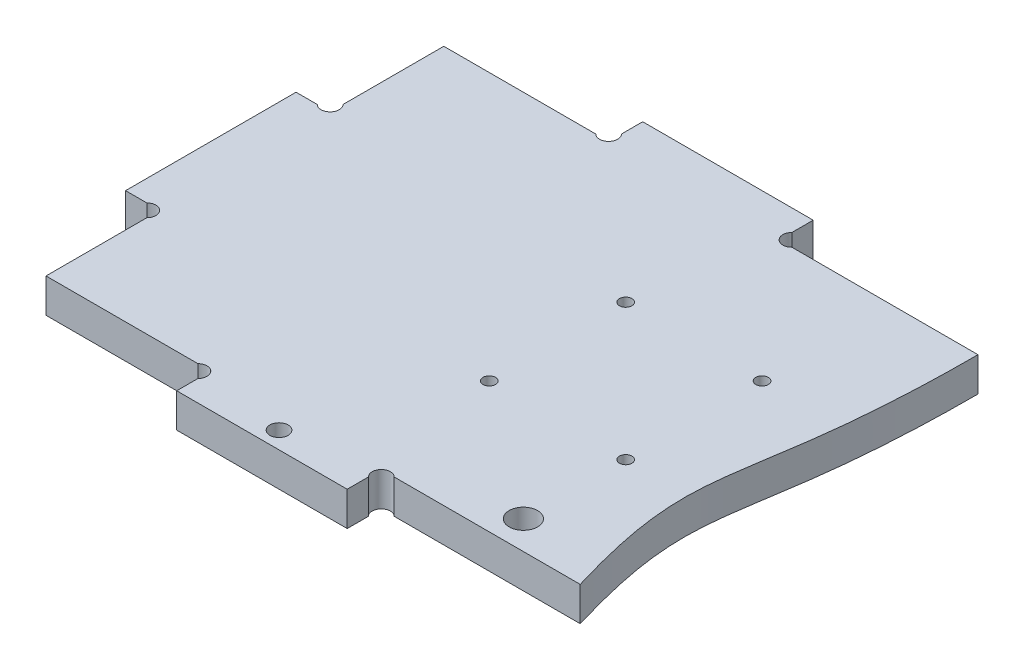
from build123d import *

# Parameters (mm, degrees)
ESQUISSE1_R        = 1.1
ESQUISSE1_R_2      = 2.5
ESQUISSE1_R_3      = 1.6
BOSS_EXTRU_1_DEPTH = 6


with BuildPart() as part:
    # Esquisse1 → Boss.-Extru.1 (new body)
    with BuildSketch(Plane(origin=(0, 0, 0), x_dir=(1, 0, 0), z_dir=(0, 1, 0))):
        with BuildLine():
            Line((35, 3.7372583), (35, 0))
            Line((35, 0), (65, 0))
            Line((65, 0), (65, 3.7372583))
            ThreePointArc((65, 3.7372583), (65, 6), (67.2627417, 6))
            Line((67.2627417, 6), (100, 6))
            add(Edge.make_bspline(
                [(100, 76), (100.002627286, 33.804168005), (90.872941061, 36.466178743), (100, 6)],
                knots=[0, 0, 0, 0, 1, 1, 1, 1], degree=3))
            Line((100, 76), (67.2627417, 76))
            ThreePointArc((67.2627417, 76), (65, 76), (65, 78.2627417))
            Line((65, 78.2627417), (65, 82))
            Line((65, 82), (35, 82))
            Line((35, 82), (35, 78.2627417))
            ThreePointArc((35, 78.2627417), (35, 76), (32.7372583, 76))
            Line((32.7372583, 76), (6, 76))
            Line((6, 76), (6, 58.2627417))
            ThreePointArc((6, 58.2627417), (6, 56), (3.7372583, 56))
            Line((3.7372583, 56), (0, 56))
            Line((0, 56), (0, 26))
            Line((0, 26), (3.7372583, 26))
            ThreePointArc((3.7372583, 26), (6, 26), (6, 23.7372583))
            Line((6, 23.7372583), (6, 6))
            Line((6, 6), (32.7372583, 6))
            ThreePointArc((32.7372583, 6), (35, 6), (35, 3.7372583))
        make_face()
        with Locations(Location((85, 53, 0), (0, 0, 270))):  # turned: the seam where the file's is
            Circle(ESQUISSE1_R, mode=Mode.SUBTRACT)
        with Locations(Location((61, 53, 0), (0, 0, 270))):  # turned: the seam where the file's is
            Circle(ESQUISSE1_R, mode=Mode.SUBTRACT)
        with Locations(Location((85, 29, 0), (0, 0, 270))):  # turned: the seam where the file's is
            Circle(ESQUISSE1_R, mode=Mode.SUBTRACT)
        with Locations(Location((61, 29, 0), (0, 0, 270))):  # turned: the seam where the file's is
            Circle(ESQUISSE1_R, mode=Mode.SUBTRACT)
        with Locations(Location((85, 11, 0), (0, 0, 270))):  # turned: the seam where the file's is
            Circle(ESQUISSE1_R_2, mode=Mode.SUBTRACT)
        with Locations(Location((50, 3, 0), (0, 0, 270))):  # turned: the seam where the file's is
            Circle(ESQUISSE1_R_3, mode=Mode.SUBTRACT)
    extrude(amount=BOSS_EXTRU_1_DEPTH)


solid = part.part
